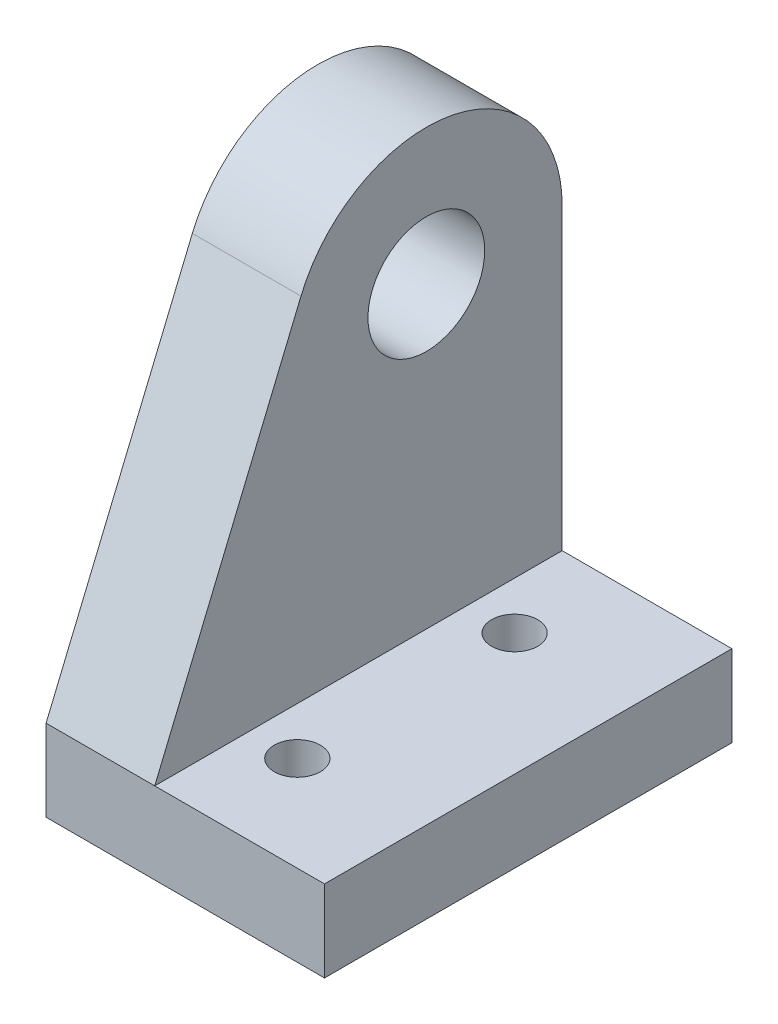
from build123d import *

# Parameters (mm, degrees)
SALIENTE_EXTRUIR1_DEPTH = 30
CROQUIS2_R              = 4.3
CORTAR_EXTRUIR1_DEPTH   = 21.5
CORTAR_EXTRUIR2_REACH   = 40
CROQUIS3_R              = 1.7


with BuildPart() as part:
    # Croquis1 → Saliente-Extruir1 (new body)
    with BuildSketch(Plane.XY):
        Polygon((0, 0), (-12.5, 0), (-12.5, 32), (-20.5, 32), (-20.5, -6), (0, -6), align=None)
    extrude(amount=SALIENTE_EXTRUIR1_DEPTH)

    # Croquis2 → Cortar-Extruir1 (cut, through all)
    with BuildSketch(Plane.ZY.offset(20.5)):
        with Locations((10, 22)):
            Circle(CROQUIS2_R)
        with BuildLine():
            Line((30, 0), (19.230769231, 25.846153846))
            ThreePointArc((19.230769231, 25.846153846), (8.038838649, 31.805806757), (0, 22))
            Line((0, 22), (0, 21))
            Line((0, 21), (-1, 21))
            Line((-1, 21), (-1, 33))
            Line((-1, 33), (31, 33))
            Line((31, 33), (31, 0))
            Line((31, 0), (30, 0))
        make_face()
    extrude(amount=-CORTAR_EXTRUIR1_DEPTH, mode=Mode.SUBTRACT)

    # Croquis3 → Cortar-Extruir2 (cut, up to next)
    with BuildSketch(Plane.XZ.offset(6), mode=Mode.PRIVATE) as cortar_extruir2_sk1:
        with Locations((-9, 23)):
            Circle(CROQUIS3_R)
    cortar_extruir2_tool1 = extrude(cortar_extruir2_sk1.sketch, amount=-CORTAR_EXTRUIR2_REACH, mode=Mode.PRIVATE) & part.part
    add(cortar_extruir2_tool1.solids().sort_by_distance((-9, -6, 23))[0], mode=Mode.SUBTRACT)
    # Croquis3 → Cortar-Extruir2 (cut, up to next)
    with BuildSketch(Plane.XZ.offset(6), mode=Mode.PRIVATE) as cortar_extruir2_sk2:
        with Locations((-9, 7)):
            Circle(CROQUIS3_R)
    cortar_extruir2_tool2 = extrude(cortar_extruir2_sk2.sketch, amount=-CORTAR_EXTRUIR2_REACH, mode=Mode.PRIVATE) & part.part
    add(cortar_extruir2_tool2.solids().sort_by_distance((-9, -6, 7))[0], mode=Mode.SUBTRACT)


solid = part.part
